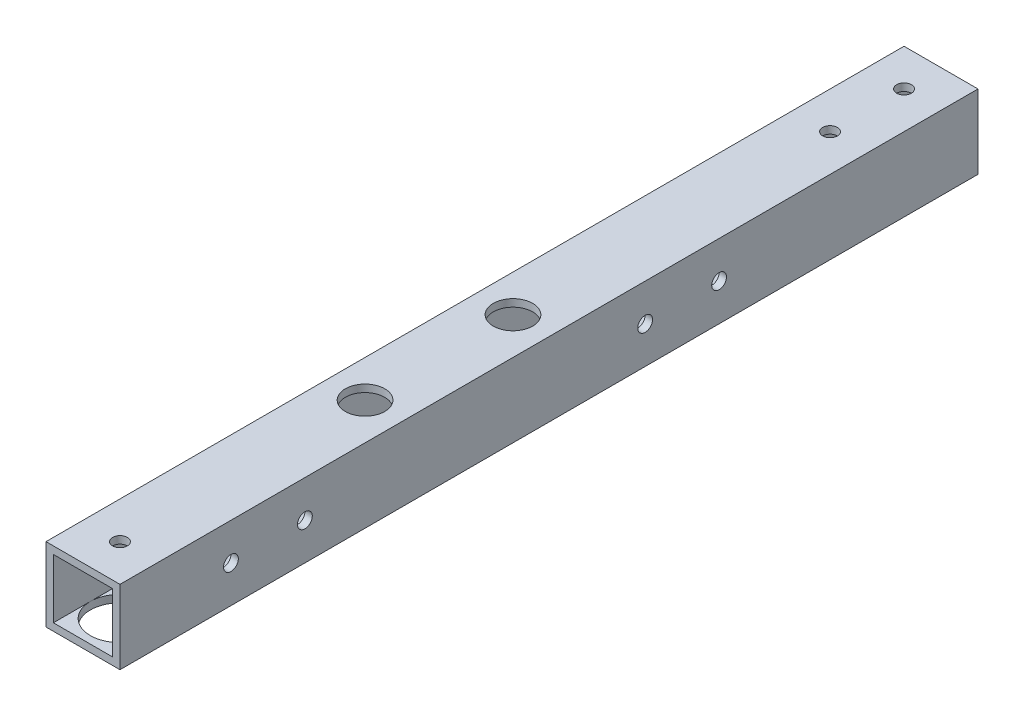
from build123d import *

# Parameters (mm, degrees)
SKETCH_1_W           = 15
SKETCH_1_H           = 15
SKETCH_1_W_2         = 12
SKETCH_1_H_2         = 12
EXTRUDE_2_DEPTH      = 174
SKETCH_3_R           = 1.5
CUT_EXTRUDE_2_DEPTH  = 10
SKETCH_6_R           = 4
CUT_EXTRUDE_4_DEPTH  = 10
SKETCH_7_R           = 1.5
CUT_EXTRUDE_5_DEPTH  = 10
SKETCH_8_R           = 4
CUT_EXTRUDE_6_DEPTH  = 10
SKETCH_10_R          = 1.5
CUT_EXTRUDE_9_DEPTH  = 10
SKETCH_13_R          = 1.5
CUT_EXTRUDE_11_DEPTH = 10
SKETCH_16_R          = 1.5
CUT_EXTRUDE_14_DEPTH = 10
SKETCH_17_R          = 6
CUT_EXTRUDE_15_DEPTH = 10
SKETCH_18_R          = 1.5
CUT_EXTRUDE_16_DEPTH = 10
SKETCH_19_R          = 4
CUT_EXTRUDE_17_DEPTH = 10
SKETCH_20_R          = 1.5
CUT_EXTRUDE_18_DEPTH = 10
SKETCH_21_R          = 1.5
CUT_EXTRUDE_19_DEPTH = 10
SKETCH_22_R          = 4
CUT_EXTRUDE_20_DEPTH = 10
SKETCH_23_R          = 1.5
CUT_EXTRUDE_21_DEPTH = 10
SKETCH_24_R          = 4
CUT_EXTRUDE_22_DEPTH = 10
SKETCH_25_R          = 4
CUT_EXTRUDE_23_DEPTH = 10
SKETCH_26_R          = 6
CUT_EXTRUDE_24_DEPTH = 10


with BuildPart() as part:
    # ｽｹｯﾁ1 → ﾎﾞｽ - 押し出し2 (new body)
    with BuildSketch(Plane.XY):
        with Locations((0.489915859, 0.232626086)):
            Rectangle(SKETCH_1_W, SKETCH_1_H)
        with Locations((0.489915859, 0.232626086)):
            Rectangle(SKETCH_1_W_2, SKETCH_1_H_2, mode=Mode.SUBTRACT)
    extrude(amount=EXTRUDE_2_DEPTH)

    # ｽｹｯﾁ3 → ｶｯﾄ - 押し出し2 (cut)
    with BuildSketch(Plane(origin=(7.989915859, 0, 0), x_dir=(0, 0, -1), z_dir=(1, 0, 0))):
        with Locations((-52.5, 0.232626086)):
            Circle(SKETCH_3_R)
    extrude(amount=-CUT_EXTRUDE_2_DEPTH, mode=Mode.SUBTRACT)

    # ｽｹｯﾁ6 → ｶｯﾄ - 押し出し4 (cut)
    with BuildSketch(Plane.ZY.offset(7.010084141)):
        with Locations((52.5, 0.232626086)):
            Circle(SKETCH_6_R)
    extrude(amount=-CUT_EXTRUDE_4_DEPTH, mode=Mode.SUBTRACT)

    # ｽｹｯﾁ7 → ｶｯﾄ - 押し出し5 (cut)
    with BuildSketch(Plane(origin=(7.989915859, 0, 0), x_dir=(0, 0, -1), z_dir=(1, 0, 0))):
        with Locations((-151.5, 0.232626086)):
            Circle(SKETCH_7_R)
    extrude(amount=-CUT_EXTRUDE_5_DEPTH, mode=Mode.SUBTRACT)

    # ｽｹｯﾁ8 → ｶｯﾄ - 押し出し6 (cut)
    with BuildSketch(Plane.ZY.offset(7.010084141)):
        with Locations((151.5, 0.232626086)):
            Circle(SKETCH_8_R)
    extrude(amount=-CUT_EXTRUDE_6_DEPTH, mode=Mode.SUBTRACT)

    # ｽｹｯﾁ10 → ｶｯﾄ - 押し出し9 (cut)
    with BuildSketch(Plane.ZY.offset(7.010084141)):
        with Locations((86.8, 0.232626086)):
            Circle(SKETCH_10_R)
    extrude(amount=-CUT_EXTRUDE_9_DEPTH, mode=Mode.SUBTRACT)

    # ｽｹｯﾁ13 → ｶｯﾄ - 押し出し11 (cut)
    with BuildSketch(Plane.ZY.offset(7.010084141)):
        with Locations((116.8, 0.232626086)):
            Circle(SKETCH_13_R)
    extrude(amount=-CUT_EXTRUDE_11_DEPTH, mode=Mode.SUBTRACT)

    # ｽｹｯﾁ16 → ｶｯﾄ - 押し出し14 (cut)
    with BuildSketch(Plane(origin=(0, 7.732626086, 0), x_dir=(1, 0, 0), z_dir=(0, 1, 0))):
        with Locations((0.489915859, -22.5)):
            Circle(SKETCH_16_R)
    extrude(amount=-CUT_EXTRUDE_14_DEPTH, mode=Mode.SUBTRACT)

    # ｽｹｯﾁ17 → ｶｯﾄ - 押し出し15 (cut)
    with BuildSketch(Plane.XZ.offset(7.267373914)):
        with Locations((0.489915859, 166.5)):
            Circle(SKETCH_17_R)
    extrude(amount=-CUT_EXTRUDE_15_DEPTH, mode=Mode.SUBTRACT)

    # ｽｹｯﾁ18 → ｶｯﾄ - 押し出し16 (cut)
    with BuildSketch(Plane(origin=(0, 7.732626086, 0), x_dir=(1, 0, 0), z_dir=(0, 1, 0))):
        with Locations((0.489915859, -166.5)):
            Circle(SKETCH_18_R)
    extrude(amount=-CUT_EXTRUDE_16_DEPTH, mode=Mode.SUBTRACT)

    # ｽｹｯﾁ19 → ｶｯﾄ - 押し出し17 (cut)
    with BuildSketch(Plane.ZY.offset(7.010084141)):
        with Locations((67.5, 0.232626086)):
            Circle(SKETCH_19_R)
    extrude(amount=-CUT_EXTRUDE_17_DEPTH, mode=Mode.SUBTRACT)

    # ｽｹｯﾁ20 → ｶｯﾄ - 押し出し18 (cut)
    with BuildSketch(Plane(origin=(7.989915859, 0, 0), x_dir=(0, 0, -1), z_dir=(1, 0, 0))):
        with Locations((-67.5, 0.232626086)):
            Circle(SKETCH_20_R)
    extrude(amount=-CUT_EXTRUDE_18_DEPTH, mode=Mode.SUBTRACT)

    # ｽｹｯﾁ21 → ｶｯﾄ - 押し出し19 (cut)
    with BuildSketch(Plane(origin=(7.989915859, 0, 0), x_dir=(0, 0, -1), z_dir=(1, 0, 0))):
        with Locations((-136.5, 0.232626086)):
            Circle(SKETCH_21_R)
    extrude(amount=-CUT_EXTRUDE_19_DEPTH, mode=Mode.SUBTRACT)

    # ｽｹｯﾁ22 → ｶｯﾄ - 押し出し20 (cut)
    with BuildSketch(Plane.ZY.offset(7.010084141)):
        with Locations((136.5, 0.232626086)):
            Circle(SKETCH_22_R)
    extrude(amount=-CUT_EXTRUDE_20_DEPTH, mode=Mode.SUBTRACT)

    # ｽｹｯﾁ23 → ｶｯﾄ - 押し出し21 (cut)
    with BuildSketch(Plane(origin=(0, 7.732626086, 0), x_dir=(1, 0, 0), z_dir=(0, 1, 0))):
        with Locations((0.489915859, -7.5)):
            Circle(SKETCH_23_R)
    extrude(amount=-CUT_EXTRUDE_21_DEPTH, mode=Mode.SUBTRACT)

    # ｽｹｯﾁ24 → ｶｯﾄ - 押し出し22 (cut)
    with BuildSketch(Plane(origin=(0, 7.732626086, 0), x_dir=(1, 0, 0), z_dir=(0, 1, 0))):
        with Locations((0.489915859, -86.8)):
            Circle(SKETCH_24_R)
    extrude(amount=-CUT_EXTRUDE_22_DEPTH, mode=Mode.SUBTRACT)

    # ｽｹｯﾁ25 → ｶｯﾄ - 押し出し23 (cut)
    with BuildSketch(Plane(origin=(0, 7.732626086, 0), x_dir=(1, 0, 0), z_dir=(0, 1, 0))):
        with Locations((0.489915859, -116.8)):
            Circle(SKETCH_25_R)
    extrude(amount=-CUT_EXTRUDE_23_DEPTH, mode=Mode.SUBTRACT)

    # ｽｹｯﾁ26 → ｶｯﾄ - 押し出し24 (cut)
    with BuildSketch(Plane.XZ.offset(7.267373914)):
        with Locations((0.489915859, 22.5)):
            Circle(SKETCH_26_R)
    extrude(amount=-CUT_EXTRUDE_24_DEPTH, mode=Mode.SUBTRACT)


solid = part.part
